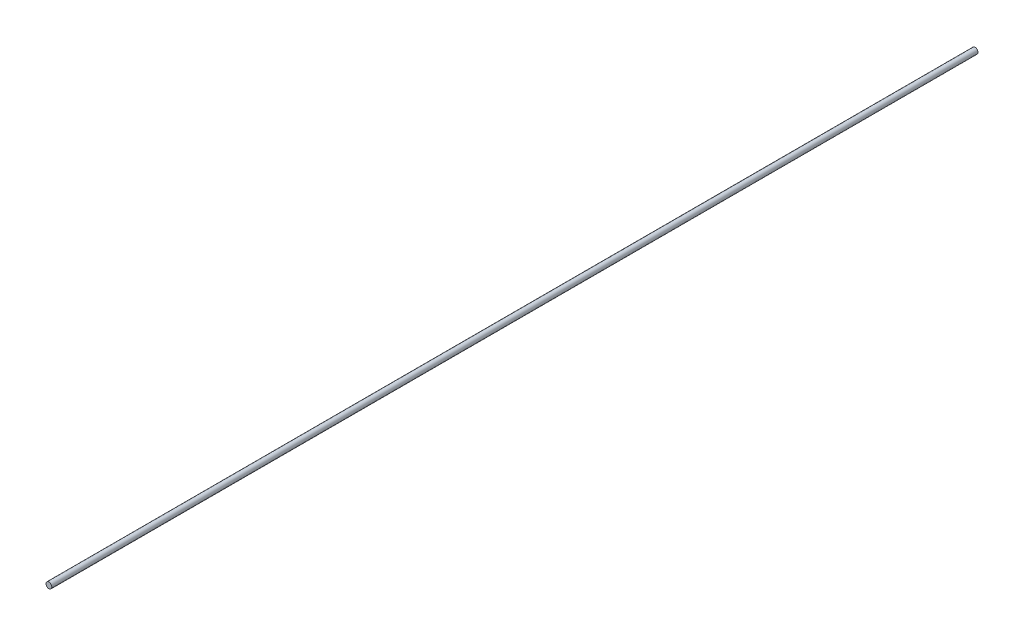
from build123d import *

# Parameters (mm, degrees)
ESQUISSE1_R        = 3
BOSS_EXTRU_1_DEPTH = 956.16


with BuildPart() as part:
    # Esquisse1 → Boss.-Extru.1 (new body)
    with BuildSketch(Plane.XY):
        Circle(ESQUISSE1_R)
    extrude(amount=BOSS_EXTRU_1_DEPTH)


solid = part.part
